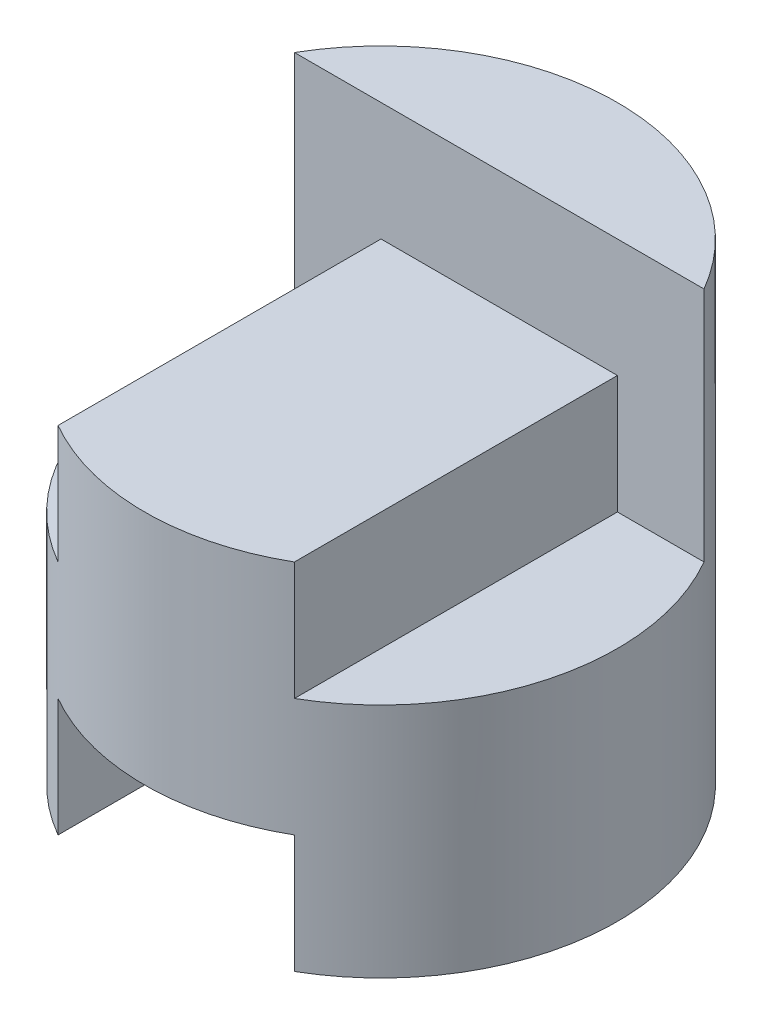
from build123d import *

# Parameters (mm, degrees)
SKETCH1_R               = 2
BOSS_EXTRUDE1_DEPTH     = 4
SKETCH2_W               = 2
SKETCH2_H               = 1
CUT_EXTRUDE1_DEPTH      = 2
CUT_EXTRUDE2_DEPTH      = 4
CUT_EXTRUDE2_DEPTH_BACK = 1


with BuildPart() as part:
    # Sketch1 → Boss-Extrude1 (new body)
    with BuildSketch(Plane(origin=(0, 0, 0), x_dir=(1, 0, 0), z_dir=(0, 1, 0))):
        Circle(SKETCH1_R)
    extrude(amount=BOSS_EXTRUDE1_DEPTH)

    # Sketch2 → Cut-Extrude1 (cut, symmetric)
    with BuildSketch(Plane.XY):
        with Locations((0, 0.5)):
            Rectangle(SKETCH2_W, SKETCH2_H)
    extrude(amount=CUT_EXTRUDE1_DEPTH, both=True, mode=Mode.SUBTRACT)

    # Sketch3 → Cut-Extrude2 (cut, two sides)
    with BuildSketch(Plane.XY) as cut_extrude2_sk:
        Polygon((-2, 4), (2, 4), (2, 3), (2, 2), (0.999776138, 2), (0.999776138, 3), (-1, 3), (-1, 2), (-2, 2), align=None)
    extrude(amount=CUT_EXTRUDE2_DEPTH, mode=Mode.SUBTRACT)
    extrude(cut_extrude2_sk.sketch, amount=-CUT_EXTRUDE2_DEPTH_BACK, mode=Mode.SUBTRACT)


solid = part.part
